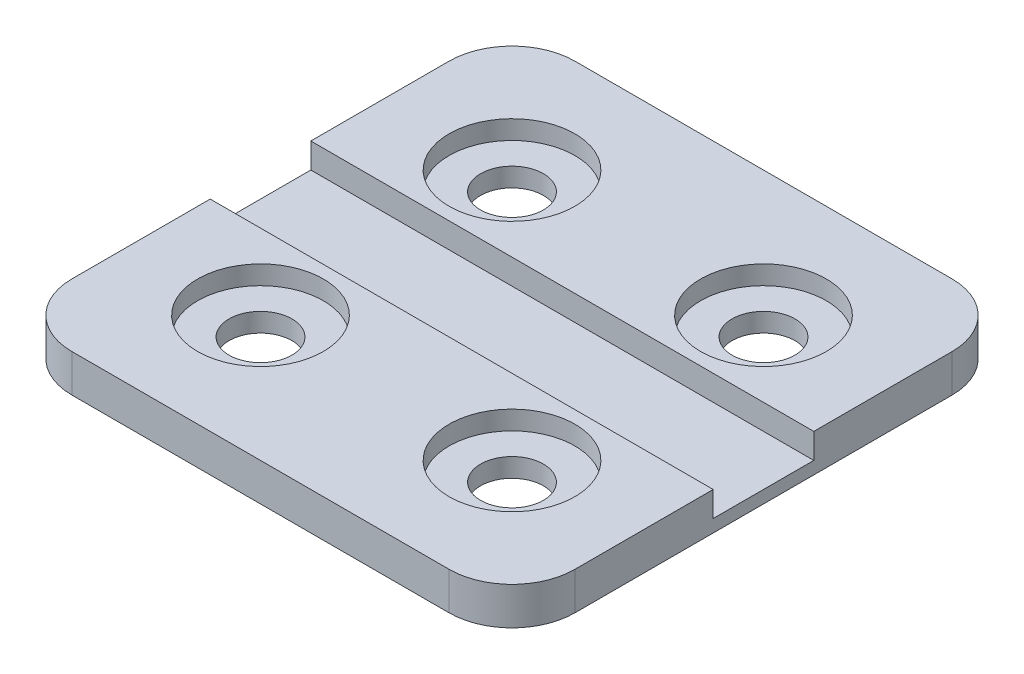
from build123d import *

# Parameters (mm, degrees)
SKETCH1_W           = 40
SKETCH1_H           = 40
BOSS_EXTRUDE1_DEPTH = 3
CUT_EXTRUDE1_DEPTH  = 1.5
SKETCH3_R           = 2.5
CUT_EXTRUDE2_DEPTH  = 2.5
FILLET1_R           = 5
SKETCH4_W           = 40
SKETCH4_H           = 8
CUT_EXTRUDE3_DEPTH  = 2


with BuildPart() as part:
    # Sketch1 → Boss-Extrude1 (new body)
    with BuildSketch(Plane(origin=(0, 0, 0), x_dir=(1, 0, 0), z_dir=(0, 1, 0))):
        Rectangle(SKETCH1_W, SKETCH1_H)
    extrude(amount=BOSS_EXTRUDE1_DEPTH)

    # Sketch2 → Cut-Extrude1 (cut)
    with BuildSketch(Plane(origin=(0, 3, 0), x_dir=(1, 0, 0), z_dir=(0, 1, 0))):
        with BuildLine():
            ThreePointArc((-5, 10), (-13.535533906, 13.535533906), (-10, 5))
            Line((-10, 5), (-10, 10))
            Line((-10, 10), (-5, 10))
        make_face()
        with BuildLine():
            Line((-10, 10), (-10, 5))
            ThreePointArc((-10, 5), (-6.464466094, 6.464466094), (-5, 10))
            Line((-5, 10), (-10, 10))
        make_face()
        with BuildLine():
            ThreePointArc((5, 10), (6.464466094, 6.464466094), (10, 5))
            Line((10, 5), (10, 10))
            Line((10, 10), (5, 10))
        make_face()
        with BuildLine():
            Line((10, 10), (10, 5))
            ThreePointArc((10, 5), (13.535533906, 6.464466094), (15, 10))
            ThreePointArc((15, 10), (10, 15), (5, 10))
            Line((5, 10), (10, 10))
        make_face()
        with BuildLine():
            Line((-10, -5), (-10, -10))
            Line((-10, -10), (-5, -10))
            ThreePointArc((-5, -10), (-6.464466094, -6.464466094), (-10, -5))
        make_face()
        with BuildLine():
            Line((-5, -10), (-10, -10))
            Line((-10, -10), (-10, -5))
            ThreePointArc((-10, -5), (-13.535533906, -13.535533906), (-5, -10))
        make_face()
        with BuildLine():
            ThreePointArc((10, -5), (6.464466094, -6.464466094), (5, -10))
            Line((5, -10), (10, -10))
            Line((10, -10), (10, -5))
        make_face()
        with BuildLine():
            Line((10, -10), (5, -10))
            ThreePointArc((5, -10), (10, -15), (15, -10))
            ThreePointArc((15, -10), (13.535533906, -6.464466094), (10, -5))
            Line((10, -5), (10, -10))
        make_face()
    extrude(amount=-CUT_EXTRUDE1_DEPTH, mode=Mode.SUBTRACT)

    # Sketch3 → Cut-Extrude2 (cut, through all)
    with BuildSketch(Plane(origin=(0, 1.5, 0), x_dir=(1, 0, 0), z_dir=(0, 1, 0))):
        with Locations((-10, 10)):
            Circle(SKETCH3_R)
        with Locations((10, 10)):
            Circle(SKETCH3_R)
        with Locations((-10, -10)):
            Circle(SKETCH3_R)
        with Locations((10, -10)):
            Circle(SKETCH3_R)
    extrude(amount=-CUT_EXTRUDE2_DEPTH, mode=Mode.SUBTRACT)

    # Fillet1
    fillet1_edges = [part.edges().sort_by_distance(p)[0] for p in [
        (20, 1.5, 20),
        (-20, 1.5, 20),
        (-20, 1.5, -20),
        (20, 1.5, -20),
    ]]
    fillet(fillet1_edges, radius=FILLET1_R)

    # Sketch4 → Cut-Extrude3 (cut)
    with BuildSketch(Plane(origin=(0, 3, 0), x_dir=(1, 0, 0), z_dir=(0, 1, 0))):
        Rectangle(SKETCH4_W, SKETCH4_H)
    extrude(amount=-CUT_EXTRUDE3_DEPTH, mode=Mode.SUBTRACT)


solid = part.part
